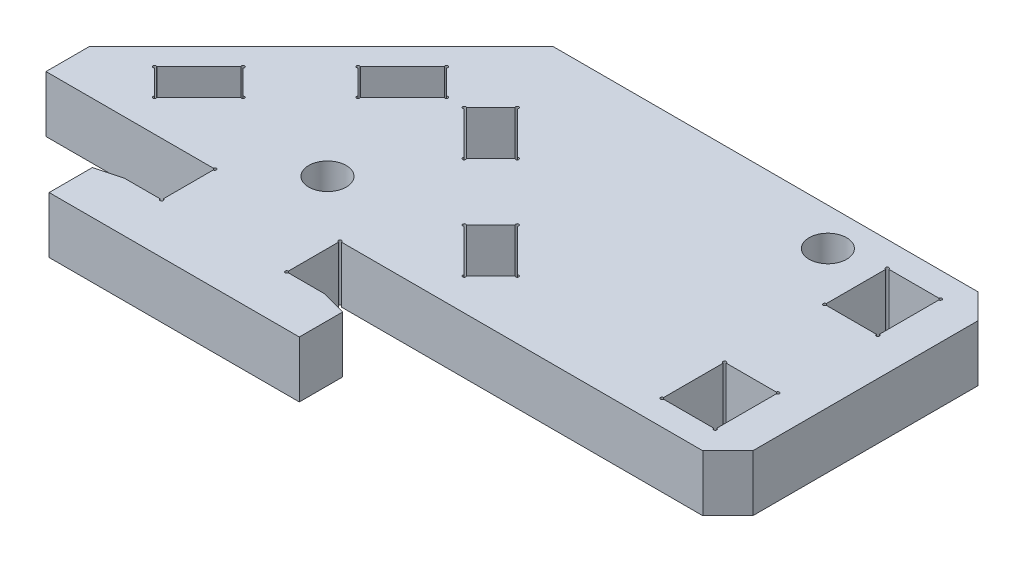
from build123d import *
from OCP.BRepFilletAPI import BRepFilletAPI_MakeChamfer

# Parameters (mm, degrees)
BOSS_EXTRUDE1_DEPTH = 4.5
CUT_EXTRUDE1_DEPTH  = 43.429353047
SKETCH3_W           = 4.25
SKETCH3_H           = 5
CUT_EXTRUDE2_DEPTH  = 43.429353047
SKETCH4_R           = 1.5
CUT_EXTRUDE3_DEPTH  = 43.429353047
BOSS_EXTRUDE2_DEPTH = 4.5
CHAMFER1_SIZE       = 2
CHAMFER1_SIZE2      = 0.535898385
CHAMFER2_SIZE       = 2
SKETCH8_R           = 0.125
CUT_EXTRUDE4_DEPTH  = 48.236770635


with BuildPart() as part:
    # Sketch1 → Boss-Extrude1 (new body)
    with BuildSketch(Plane(origin=(0, 0, 0), x_dir=(1, 0, 0), z_dir=(0, 1, 0))):
        Polygon((-18.5, -18.5), (0, 0), (36, 0), (36, -22), (-18.5, -22), align=None)
    extrude(amount=BOSS_EXTRUDE1_DEPTH)

    # Sketch2 → Cut-Extrude1 (cut, through all)
    with BuildSketch(Plane(origin=(0, 4.5, 0), x_dir=(1, 0, 0), z_dir=(0, 1, 0))):
        Polygon((-6.363961031, -9.192388155), (-2.828427125, -5.656854249), (-0.707106781, -7.778174593), (-4.242640687, -11.313708499), align=None)
        Polygon((-10.960155108, -13.788582233), (-8.838834765, -15.909902577), (-12.374368671, -19.445436483), (-14.495689014, -17.324116139), align=None)
    cut_extrude1 = extrude(amount=-CUT_EXTRUDE1_DEPTH, mode=Mode.SUBTRACT)

    # Mirror1: Cut-Extrude1 across plane
    add(cut_extrude1.mirror(Plane(origin=(0, 0, 0), x_dir=(0, 0, 1), z_dir=(1, 0, 0))), mode=Mode.SUBTRACT)

    # Sketch3 → Cut-Extrude2 (cut, through all)
    with BuildSketch(Plane(origin=(0, 4.5, 0), x_dir=(1, 0, 0), z_dir=(0, 1, 0))):
        with Locations((30.875, -4.5)):
            Rectangle(SKETCH3_W, SKETCH3_H)
        with Locations((30.875, -17.5)):
            Rectangle(SKETCH3_W, SKETCH3_H)
    extrude(amount=-CUT_EXTRUDE2_DEPTH, mode=Mode.SUBTRACT)

    # Sketch4 → Cut-Extrude3 (cut, through all)
    with BuildSketch(Plane(origin=(0, 4.5, 0), x_dir=(1, 0, 0), z_dir=(0, 1, 0))):
        with Locations(Location((0, -18, 0), (0, 0, 270))):
            Circle(SKETCH4_R)
        with Locations(Location((25, -3, 0), (0, 0, 270))):
            Circle(SKETCH4_R)
    extrude(amount=-CUT_EXTRUDE3_DEPTH, mode=Mode.SUBTRACT)

    # Sketch5 → Boss-Extrude2 (add)
    with BuildSketch(Plane(origin=(0, 4.5, 0), x_dir=(1, 0, 0), z_dir=(0, 1, 0))):
        Polygon((-5, -22), (5, -22), (5, -26.25), (10, -26.25), (10, -30.25), (-10, -30.25), (-10, -26.25), (-5, -26.25), align=None)
    extrude(amount=-BOSS_EXTRUDE2_DEPTH)

    # Chamfer1: one chamfer whose edges measure the first distance from different faces: ONE call of the kernel's chamfer builder (chamfer() names one face for all edges)
    chamfer1_edges_1 = [part.edges().sort_by_distance(p)[0] for p in [
        (-10, 2.25, 26.25),
    ]]
    chamfer1_side_1 = [part.faces().sort_by_distance(p)[0] for p in [
        (-7.5, 2.25, 26.25),
    ]]
    chamfer1_edges_2 = [part.edges().sort_by_distance(p)[0] for p in [
        (10, 2.25, 26.25),
    ]]
    chamfer1_side_2 = [part.faces().sort_by_distance(p)[0] for p in [
        (7.5, 2.25, 26.25),
    ]]
    chamfer1 = BRepFilletAPI_MakeChamfer(part.part.solid().wrapped)
    for e in chamfer1_edges_1:
        chamfer1.Add(CHAMFER1_SIZE, CHAMFER1_SIZE2, e.wrapped, chamfer1_side_1[0].wrapped)  # the first distance lies on this face
    for e in chamfer1_edges_2:
        chamfer1.Add(CHAMFER1_SIZE, CHAMFER1_SIZE2, e.wrapped, chamfer1_side_2[0].wrapped)  # the first distance lies on this face
    add(Compound.cast(chamfer1.Shape()), mode=Mode.REPLACE)

    # Chamfer2
    chamfer2_edges = [part.edges().sort_by_distance(p)[0] for p in [
        (36, 2.25, 0),
        (36, 2.25, 22),
    ]]
    chamfer(chamfer2_edges, length=CHAMFER2_SIZE)

    # Sketch8 → Cut-Extrude4 (cut, through all)
    with BuildSketch(Plane(origin=(0, 4.5, 0), x_dir=(1, 0, 0), z_dir=(0, 1, 0))):
        with Locations((-12.374368671, -19.445436483)):
            Circle(SKETCH8_R)
    cut_extrude4 = extrude(amount=-CUT_EXTRUDE4_DEPTH, mode=Mode.SUBTRACT)

    # Sketch-Pattern1: Cut-Extrude4 at 27 more places
    with Locations((-2.12132, 0, -2.12132), (1.414214, 0, -5.656854), (3.535534, 0, -3.535534), (8.131728, 0, -8.131728), (6.010408, 0, -10.253048), (9.545942, 0, -13.788582), (11.667262, 0, -11.667262), (13.081475, 0, -11.667262), (15.202796, 0, -13.788582), (18.73833, 0, -10.253048), (16.617009, 0, -8.131728), (23.334524, 0, -5.656854), (21.213203, 0, -3.535534), (24.748737, 0, 0), (26.870058, 0, -2.12132), (41.124369, 0, -12.445436), (41.124369, 0, -17.445436), (45.374369, 0, -17.445436), (45.374369, 0, -12.445436), (45.374369, 0, -4.445436), (41.124369, 0, -4.445436), (41.124369, 0, 0.554564), (45.374369, 0, 0.554564), (17.374369, 0, 6.804564), (7.374369, 0, 6.804564), (7.374369, 0, 2.554564), (17.374369, 0, 2.554564)):
        add(cut_extrude4, mode=Mode.SUBTRACT)


solid = part.part
